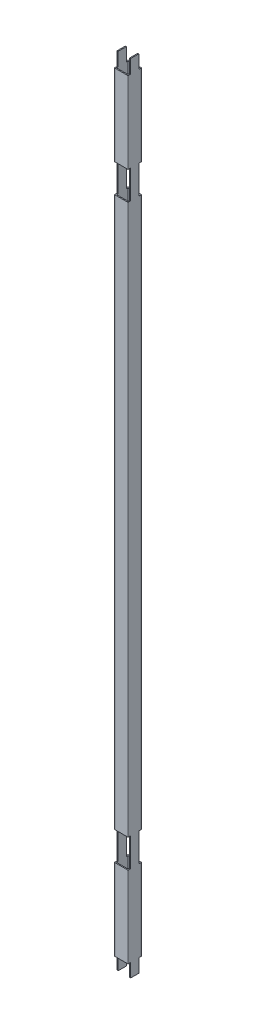
from build123d import *

# Parameters (mm, degrees)
SKETCH1_W           = 17
SKETCH1_H           = 17
BOSS_EXTRUDE1_DEPTH = 1177
SKETCH3_W           = 4
SKETCH3_H           = 20
CUT_EXTRUDE2_DEPTH  = 977
SKETCH2_W           = 4
SKETCH2_H           = 42.2
CUT_EXTRUDE1_DEPTH  = 1178.339798019


with BuildPart() as part:
    # Sketch1 → Boss-Extrude1 (new body)
    with BuildSketch(Plane(origin=(0, 0, 0), x_dir=(1, 0, 0), z_dir=(0, 1, 0))):
        with BuildLine():
            Line((0.5, 0), (19.5, 0))
            ThreePointArc((19.5, 0), (19.853553391, 0.146446609), (20, 0.5))
            Line((20, 0.5), (20, 19.5))
            ThreePointArc((20, 19.5), (19.853553391, 19.853553391), (19.5, 20))
            Line((19.5, 20), (0.5, 20))
            ThreePointArc((0.5, 20), (0.146446609, 19.853553391), (0, 19.5))
            Line((0, 19.5), (0, 0.5))
            ThreePointArc((0, 0.5), (0.146446609, 0.146446609), (0.5, 0))
        make_face()
        with Locations((10, 10)):
            Rectangle(SKETCH1_W, SKETCH1_H, mode=Mode.SUBTRACT)
    extrude(amount=BOSS_EXTRUDE1_DEPTH)

    # Sketch3 → Cut-Extrude2 (cut)
    with BuildSketch(Plane.ZY):
        with Locations((-2, 1167)):
            Rectangle(SKETCH3_W, SKETCH3_H)
        with Locations((-18, 1167)):
            Rectangle(SKETCH3_W, SKETCH3_H)
    cut_extrude2 = extrude(amount=-CUT_EXTRUDE2_DEPTH, mode=Mode.SUBTRACT)

    # Sketch2 → Cut-Extrude1 (cut, through all)
    with BuildSketch(Plane.ZY):
        with Locations((-2, 1015.9)):
            Rectangle(SKETCH2_W, SKETCH2_H)
        with Locations((-18, 1015.9)):
            Rectangle(SKETCH2_W, SKETCH2_H)
    cut_extrude1 = extrude(amount=-CUT_EXTRUDE1_DEPTH, mode=Mode.SUBTRACT)

    # Mirror1: Cut-Extrude2, Cut-Extrude1 across plane
    add(cut_extrude2.mirror(Plane.ZX.offset(588.5)), mode=Mode.SUBTRACT)
    add(cut_extrude1.mirror(Plane.ZX.offset(588.5)), mode=Mode.SUBTRACT)


solid = part.part
